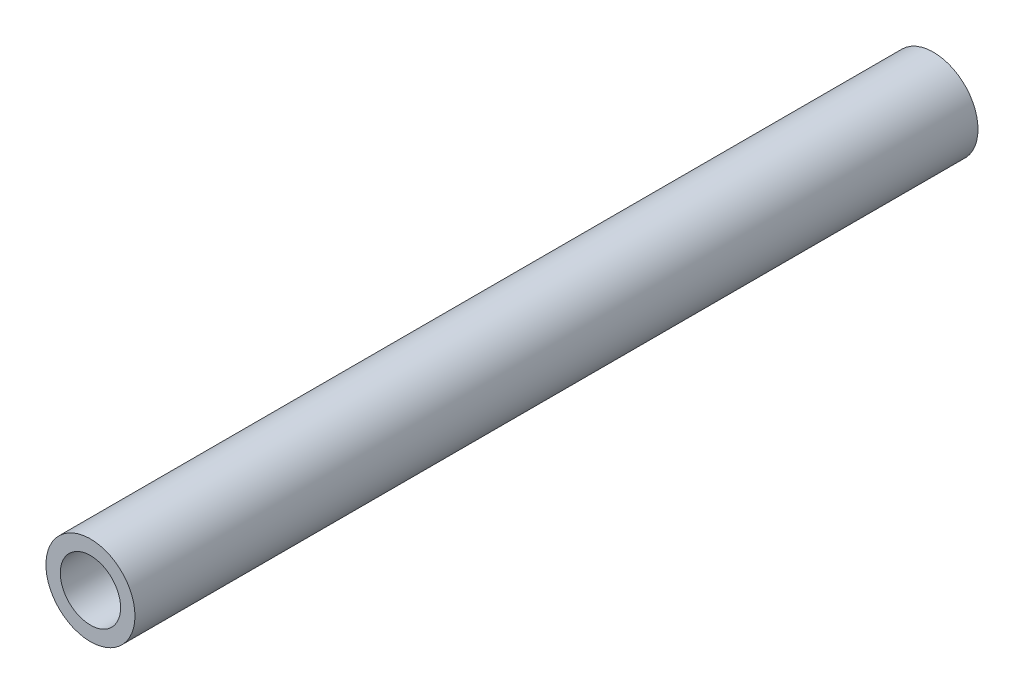
from build123d import *

# Parameters (mm, degrees)
SKETCH1_R           = 9.525
SKETCH1_R_2         = 6.45
BOSS_EXTRUDE1_DEPTH = 180.34


with BuildPart() as part:
    # Sketch1 → Boss-Extrude1 (new body)
    with BuildSketch(Plane.XY):
        Circle(SKETCH1_R)
        Circle(SKETCH1_R_2, mode=Mode.SUBTRACT)
    extrude(amount=BOSS_EXTRUDE1_DEPTH)


solid = part.part
